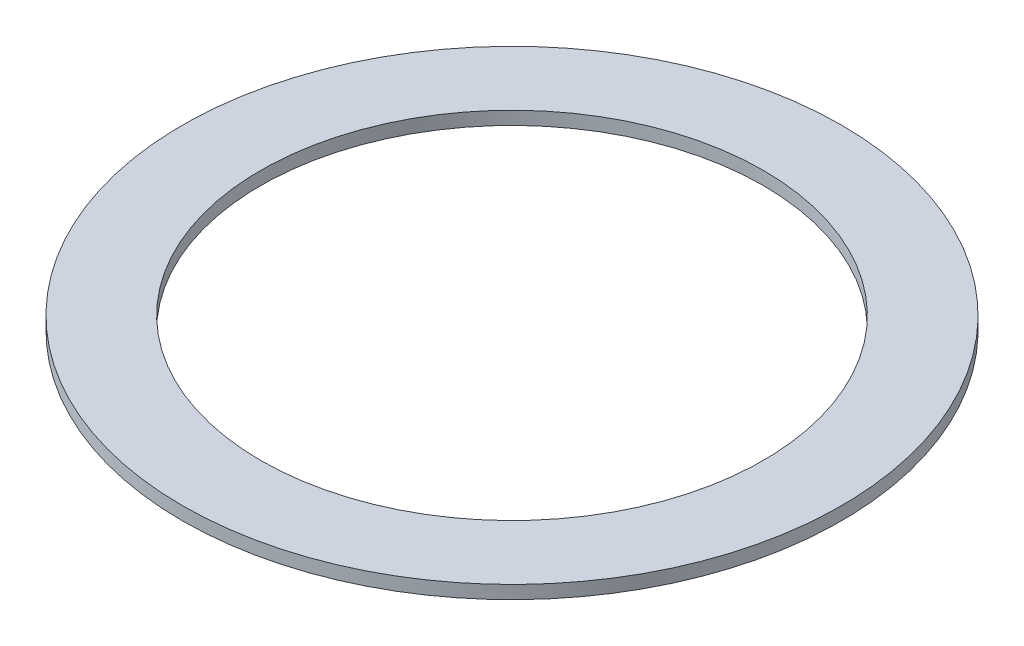
from build123d import *

# Parameters (mm, degrees)
SKETCH1_R           = 10
SKETCH1_R_2         = 7.625
BOSS_EXTRUDE1_DEPTH = 0.4


with BuildPart() as part:
    # Sketch1 → Boss-Extrude1 (new body)
    with BuildSketch(Plane(origin=(0, 0, 0), x_dir=(1, 0, 0), z_dir=(0, 1, 0))):
        Circle(SKETCH1_R)
        Circle(SKETCH1_R_2, mode=Mode.SUBTRACT)
    extrude(amount=BOSS_EXTRUDE1_DEPTH)


solid = part.part
